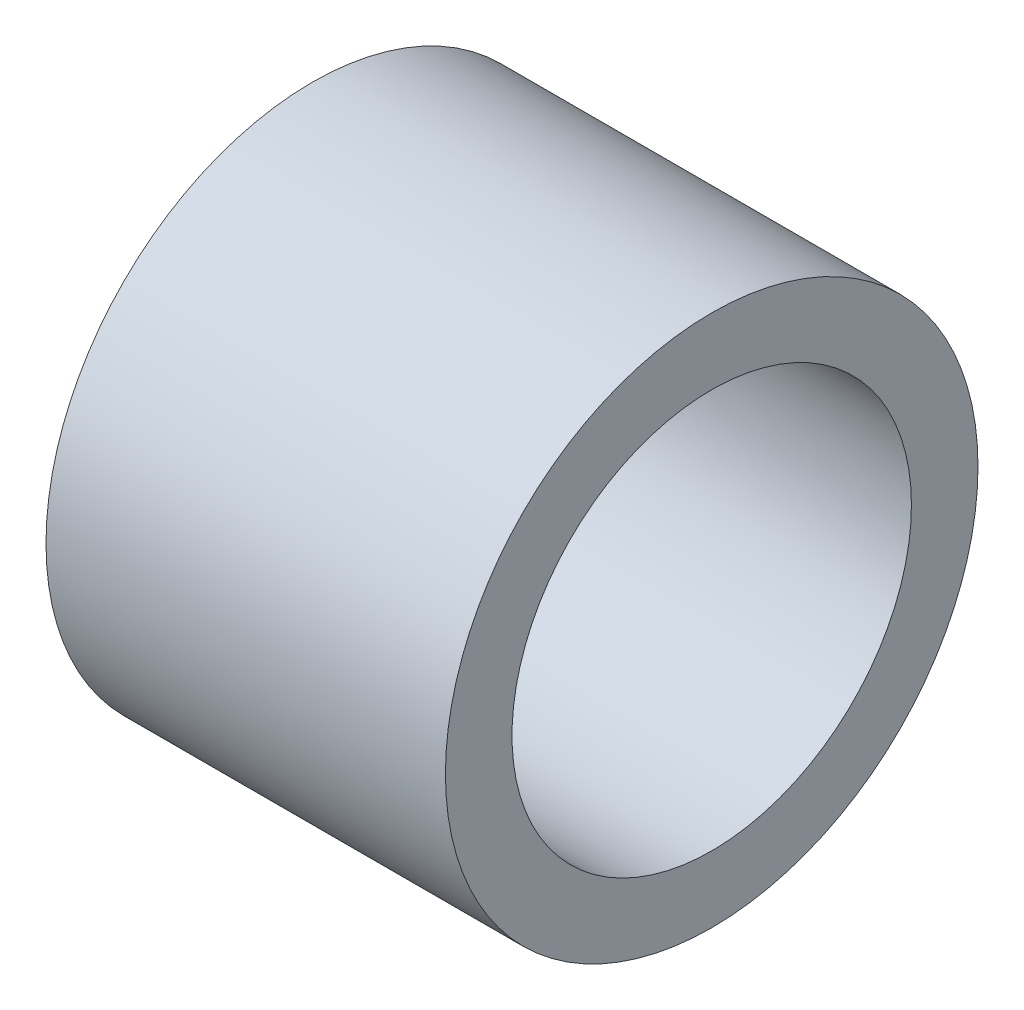
from build123d import *

# Parameters (mm, degrees)
SKETCH1_R           = 12.7
SKETCH1_R_2         = 9.525
BOSS_EXTRUDE1_DEPTH = 9.525


with BuildPart() as part:
    # Sketch1 → Boss-Extrude1 (new body, symmetric)
    with BuildSketch(Plane(origin=(0, 0, 0), x_dir=(0, 0, -1), z_dir=(1, 0, 0))):
        Circle(SKETCH1_R)
        Circle(SKETCH1_R_2, mode=Mode.SUBTRACT)
    extrude(amount=BOSS_EXTRUDE1_DEPTH, both=True)


solid = part.part
